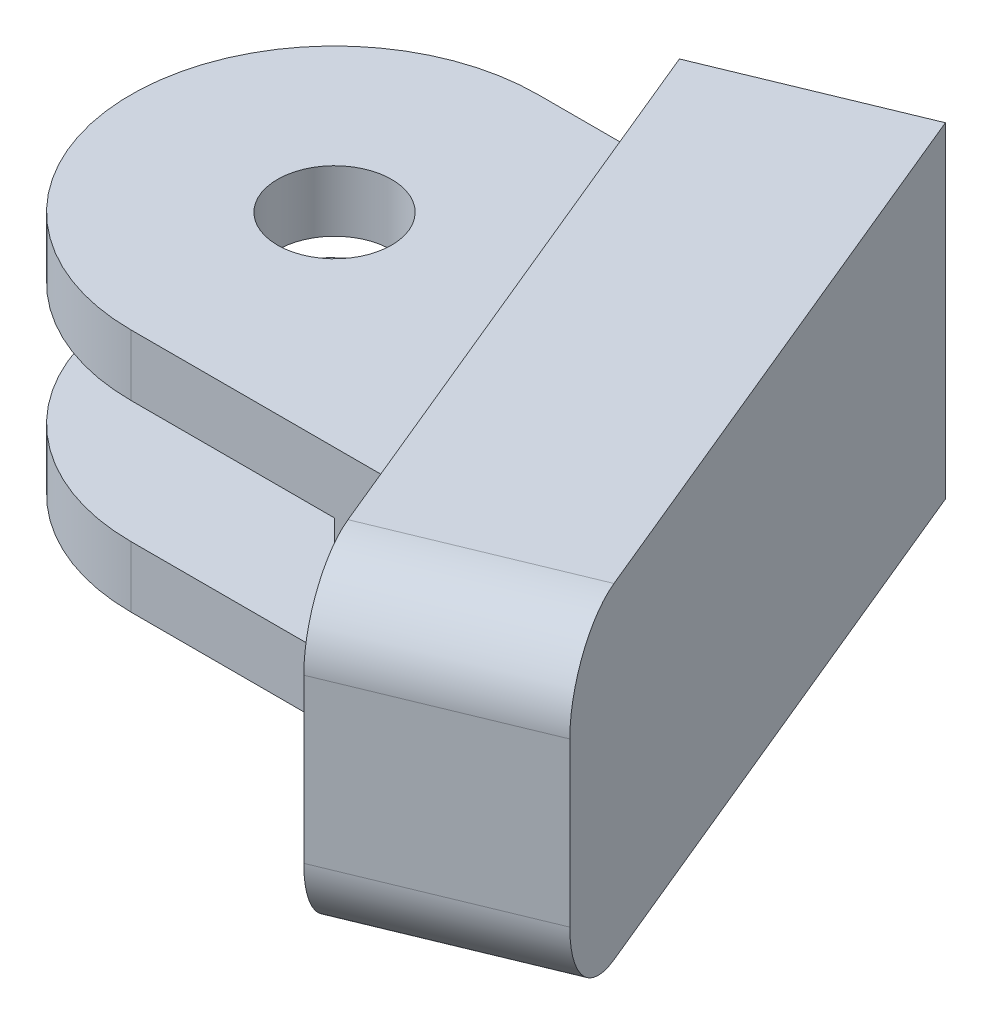
from build123d import *

# Parameters (mm, degrees)
BOSS_EXTRUDE1_DEPTH          = 5
SKETCH2_R                    = 5
SKETCH2_R_2                  = 1.4
BOSS_EXTRUDE2_DEPTH          = 1.5
BOSS_EXTRUDE3_REACH          = 13.576
SKETCH4_W                    = 10
SKETCH4_H                    = 1.5
SKETCH6_R                    = 5
SKETCH6_R_2                  = 1.4
BOSS_EXTRUDE4_DEPTH          = 1.5
BOSS_EXTRUDE5_REACH          = 13.576
SKETCH5_W                    = 10
SKETCH5_H                    = 1.5
SCHIZZO1_W                   = 10
SCHIZZO1_H                   = 6
ESTRUSIONE_ESTRUSIONE2_DEPTH = 11
TAGLIO_ESTRUSIONE1_DEPTH     = 11
ESTRUSIONE_ESTRUSIONE3_DEPTH = 5
SCHIZZO4_R                   = 6
TAGLIO_ESTRUSIONE2_DEPTH     = 3


with BuildPart() as part:
    # Sketch1 → Boss-Extrude1 (new, symmetric)
    with BuildSketch(Plane.XY):
        with BuildLine():
            Line((0, 3), (0, 1.5))
            ThreePointArc((0, 1.5), (1.5, 0), (0, -1.5))
            Line((0, -1.5), (0, -3))
            ThreePointArc((0, -3), (3, 0), (0, 3))
        make_face()
    extrude(amount=BOSS_EXTRUDE1_DEPTH, both=True)


with BuildPart() as body_2:
    # Sketch2 → Boss-Extrude2 (new body)
    with BuildSketch(Plane(origin=(0, 1.5, 0), x_dir=(1, 0, 0), z_dir=(0, 1, 0))):
        with Locations(Location((-5, 0, 0), (0, 0, 270))):
            Circle(SKETCH2_R)
        with Locations(Location((-5, 0, 0), (0, 0, 270))):
            Circle(SKETCH2_R_2, mode=Mode.SUBTRACT)
    extrude(amount=BOSS_EXTRUDE2_DEPTH)

    # Sketch4 → Boss-Extrude3 (add, up to next)
    with BuildSketch(Plane.ZY, mode=Mode.PRIVATE) as boss_extrude3_sk1:
        with Locations((0, 2.25)):
            Rectangle(SKETCH4_W, SKETCH4_H)
    boss_extrude3_tool1 = extrude(boss_extrude3_sk1.sketch, amount=BOSS_EXTRUDE3_REACH, mode=Mode.PRIVATE) - body_2.part

    add(part.part)  # Boss-Extrude3 merges part
    add(boss_extrude3_tool1.solids().sort_by_distance((0, 2.25, 0))[0])
    add(boss_extrude3_tool1.solids().sort_by_distance((0, 2.25, 0))[1])


with BuildPart() as body_2_2:
    # Sketch6 → Boss-Extrude4 (new body)
    with BuildSketch(Plane(origin=(0, -1.5, 0), x_dir=(1, 0, 0), z_dir=(0, 1, 0))):
        with Locations(Location((-5, 0, 0), (0, 0, 270))):
            Circle(SKETCH6_R)
        with Locations(Location((-5, 0, 0), (0, 0, 270))):
            Circle(SKETCH6_R_2, mode=Mode.SUBTRACT)
    extrude(amount=-BOSS_EXTRUDE4_DEPTH)

    # Sketch5 → Boss-Extrude5 (add, up to next)
    with BuildSketch(Plane.ZY, mode=Mode.PRIVATE) as boss_extrude5_sk1:
        with Locations((0, -2.25)):
            Rectangle(SKETCH5_W, SKETCH5_H)
    boss_extrude5_tool1 = extrude(boss_extrude5_sk1.sketch, amount=BOSS_EXTRUDE5_REACH, mode=Mode.PRIVATE) - body_2_2.part

    add(body_2.part)  # Boss-Extrude5 merges body 2
    add(boss_extrude5_tool1.solids().sort_by_distance((0, -2.25, 0))[0])
    add(boss_extrude5_tool1.solids().sort_by_distance((0, -2.25, 0))[1])

    # Schizzo1 → Estrusione-Estrusione2 (add)
    with BuildSketch(Plane.ZY):
        Rectangle(SCHIZZO1_W, SCHIZZO1_H)
    extrude(amount=-ESTRUSIONE_ESTRUSIONE2_DEPTH)

    # Schizzo2 → Taglio-Estrusione1 (cut)
    with BuildSketch(Plane.XZ.offset(3)):
        Polygon((3, -5), (7.130949903, 5), (11, 5), (13.561973645, 5), (13.561973645, -5), align=None)
    extrude(amount=-TAGLIO_ESTRUSIONE1_DEPTH, mode=Mode.SUBTRACT)

    # Schizzo3 → Estrusione-Estrusione3 (add)
    with BuildSketch(Plane(origin=(4.327071195, 0, -1.787491434), x_dir=(-0.3818008251213657, 0, -0.9242446266744776), z_dir=(0.9242446266744775, 0, -0.38180082512136565))):
        with BuildLine():
            Line((-7.84382569, 4), (7.15617431, 4))
            Line((7.15617431, 4), (7.15617431, -4))
            Line((7.15617431, -4), (-7.84382569, -4))
            ThreePointArc((-7.84382569, -4), (-9.258039253, -3.414213562), (-9.84382569, -2))
            Line((-9.84382569, -2), (-9.84382569, 2))
            ThreePointArc((-9.84382569, 2), (-9.258039253, 3.414213562), (-7.84382569, 4))
        make_face()
    extrude(amount=-ESTRUSIONE_ESTRUSIONE3_DEPTH)

    # Schizzo4 → Taglio-Estrusione2 (cut)
    with BuildSketch(Plane.XZ.offset(-1.5)):
        with Locations((-5, 0)):
            Circle(SCHIZZO4_R)
    extrude(amount=TAGLIO_ESTRUSIONE2_DEPTH, mode=Mode.SUBTRACT)


solid = body_2_2.part
